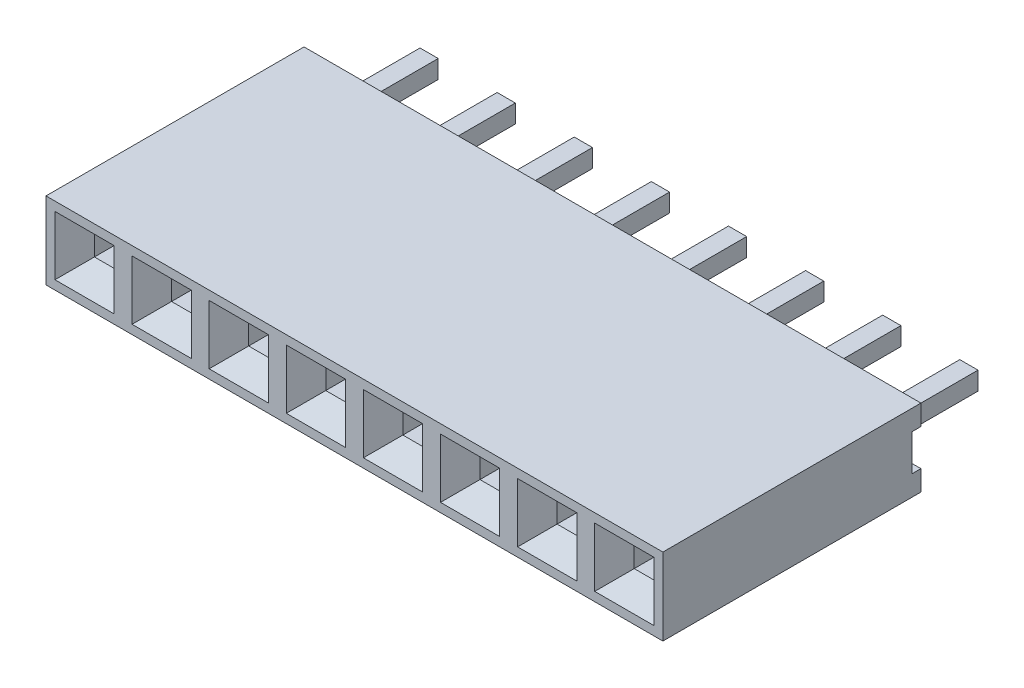
from build123d import *

# Parameters (mm, degrees)
SKETCH_1_W                         = 20.32
SKETCH_1_H                         = 2.54
EXTRUDE_1_DEPTH                    = 8.5
SKETCH_2_W                         = 0.65
SKETCH_2_H                         = 0.65
CUT_EXTRUDE_1_DEPTH                = 9.5
CHAMFER_3_SIZE                     = 0.65
PATTERN_LINEAR_4_COUNT             = 8
PATTERN_LINEAR_4_PITCH             = 2.54
CHAMFER_3_OF_PATTERN_LINEAR_4_SIZE = 0.65
SKETCH_4_W                         = 0.3
SKETCH_4_H                         = 1.2
CUT_EXTRUDE_2_DEPTH                = 21.32
SKETCH_3_W                         = 0.6
SKETCH_3_H                         = 0.6
EXTRUDE_2_DEPTH                    = 3
CHAMFER_4_SIZE                     = 0.15
PATTERN_LINEAR_5_COUNT             = 8
PATTERN_LINEAR_5_PITCH             = 2.54


with BuildPart() as part:
    # Эскиз1 → Бобышка-Вытянуть1 (new body)
    with BuildSketch(Plane.XY):
        with Locations((8.89, 0)):
            Rectangle(SKETCH_1_W, SKETCH_1_H)
    extrude(amount=EXTRUDE_1_DEPTH)

    # Эскиз2 → Вырез-Вытянуть1 (cut, through all)
    with BuildSketch(Plane.XY.offset(8.5)):
        Rectangle(SKETCH_2_W, SKETCH_2_H)
    cut_extrude_1 = extrude(amount=-CUT_EXTRUDE_1_DEPTH, mode=Mode.SUBTRACT)

    # Фаска3
    chamfer_3_edges = [part.edges().sort_by_distance(p)[0] for p in [
        (-0.325, 0, 8.5),
        (0, -0.325, 8.5),
        (0.325, 0, 8.5),
        (0, 0.325, 8.5),
    ]]
    chamfer(chamfer_3_edges, length=CHAMFER_3_SIZE)

    # Линейный массив4: Вырез-Вытянуть1 ×8
    with Locations(*[(i * PATTERN_LINEAR_4_PITCH, 0, 0) for i in range(1, PATTERN_LINEAR_4_COUNT)]):
        add(cut_extrude_1, mode=Mode.SUBTRACT)

    # Фаска3 of Линейный массив4
    chamfer_3_of_pattern_linear_4_edges = [part.edges().sort_by_distance(p)[0] for p in [
        (2.215, 0, 8.5),
        (2.54, -0.325, 8.5),
        (2.865, 0, 8.5),
        (2.54, 0.325, 8.5),
        (4.755, 0, 8.5),
        (5.08, -0.325, 8.5),
        (5.405, 0, 8.5),
        (5.08, 0.325, 8.5),
        (7.295, 0, 8.5),
        (7.62, -0.325, 8.5),
        (7.945, 0, 8.5),
        (7.62, 0.325, 8.5),
        (9.835, 0, 8.5),
        (10.16, -0.325, 8.5),
        (10.485, 0, 8.5),
        (10.16, 0.325, 8.5),
        (12.375, 0, 8.5),
        (12.7, -0.325, 8.5),
        (13.025, 0, 8.5),
        (12.7, 0.325, 8.5),
        (14.915, 0, 8.5),
        (15.24, -0.325, 8.5),
        (15.565, 0, 8.5),
        (15.24, 0.325, 8.5),
        (17.455, 0, 8.5),
        (17.78, -0.325, 8.5),
        (18.105, 0, 8.5),
        (17.78, 0.325, 8.5),
    ]]
    chamfer(chamfer_3_of_pattern_linear_4_edges, length=CHAMFER_3_OF_PATTERN_LINEAR_4_SIZE)

    # Эскиз4 → Вырез-Вытянуть2 (cut, through all)
    with BuildSketch(Plane.ZY.offset(1.27)):
        with Locations((0.15, 0)):
            Rectangle(SKETCH_4_W, SKETCH_4_H)
    extrude(amount=-CUT_EXTRUDE_2_DEPTH, mode=Mode.SUBTRACT)


with BuildPart() as body_2:
    # Эскиз3 → Бобышка-Вытянуть2 (new body, symmetric)
    with BuildSketch(Plane(origin=(0, 0, 0), x_dir=(-1, 0, 0), z_dir=(0, 0, -1))):
        Rectangle(SKETCH_3_W, SKETCH_3_H)
    extrude(amount=EXTRUDE_2_DEPTH, both=True)

    # Фаска4
    chamfer_4_edges = [body_2.edges().sort_by_distance(p)[0] for p in [
        (0, 0.3, -3),
        (-0.3, 0, -3),
        (0.3, 0, -3),
        (0, -0.3, -3),
    ]]
    chamfer(chamfer_4_edges, length=CHAMFER_4_SIZE)


with BuildPart() as pattern_linear_5_1:
    # Линейный массив5: pattern copy
    add(body_2.part.moved(Location(Vector(1, 0, 0) * (1 * PATTERN_LINEAR_5_PITCH))))


with BuildPart() as pattern_linear_5_2:
    # Линейный массив5: pattern copy
    add(body_2.part.moved(Location(Vector(1, 0, 0) * (2 * PATTERN_LINEAR_5_PITCH))))


with BuildPart() as pattern_linear_5_3:
    # Линейный массив5: pattern copy
    add(body_2.part.moved(Location(Vector(1, 0, 0) * (3 * PATTERN_LINEAR_5_PITCH))))


with BuildPart() as pattern_linear_5_4:
    # Линейный массив5: pattern copy
    add(body_2.part.moved(Location(Vector(1, 0, 0) * (4 * PATTERN_LINEAR_5_PITCH))))


with BuildPart() as pattern_linear_5_5:
    # Линейный массив5: pattern copy
    add(body_2.part.moved(Location(Vector(1, 0, 0) * (5 * PATTERN_LINEAR_5_PITCH))))


with BuildPart() as pattern_linear_5_6:
    # Линейный массив5: pattern copy
    add(body_2.part.moved(Location(Vector(1, 0, 0) * (6 * PATTERN_LINEAR_5_PITCH))))


with BuildPart() as pattern_linear_5_7:
    # Линейный массив5: pattern copy
    add(body_2.part.moved(Location(Vector(1, 0, 0) * (7 * PATTERN_LINEAR_5_PITCH))))


solid = Compound([part.part, body_2.part, pattern_linear_5_1.part, pattern_linear_5_2.part, pattern_linear_5_3.part, pattern_linear_5_4.part, pattern_linear_5_5.part, pattern_linear_5_6.part, pattern_linear_5_7.part])
